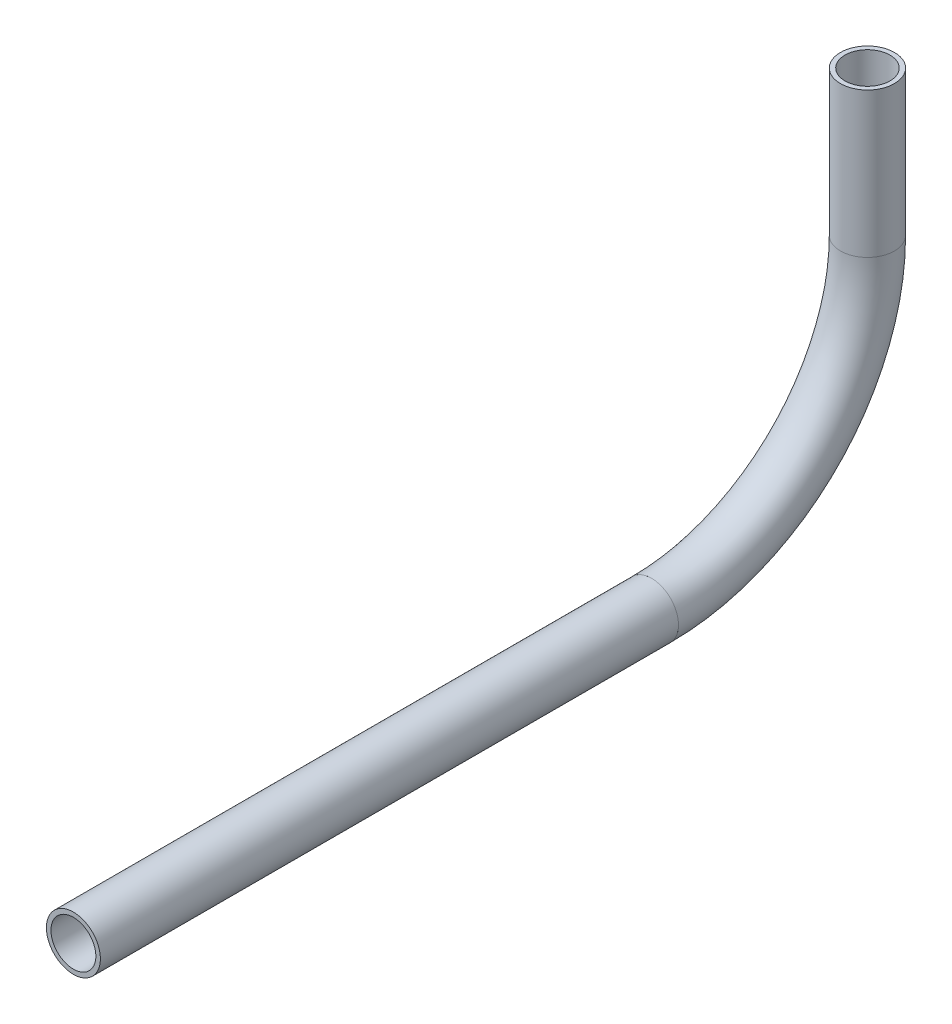
from build123d import *

# Parameters (mm, degrees)
SKETCH11_R                = 6.35
SKETCH11_R_2              = 5.2832
PIPE_0_5_SCH_40_1_DEPTH   = 136.005637638
SKETCH11_ON_SEGMENT_2_R   = 6.35
SKETCH11_ON_SEGMENT_2_R_2 = 5.2832
PIPE_0_5_SCH_40_1_2_ANGLE = 90
SKETCH11_ON_SEGMENT_3_R   = 6.35
SKETCH11_ON_SEGMENT_3_R_2 = 5.2832
PIPE_0_5_SCH_40_1_3_DEPTH = 34.109012351


with BuildPart() as part:
    # Sketch11 → Pipe 0.5 SCH 40(1) (new body)
    with BuildSketch(Plane(origin=(0, 599.960019272, 303.164595711), x_dir=(0, 1, 0), z_dir=(0, 0, -1))):
        Circle(SKETCH11_R)
        Circle(SKETCH11_R_2, mode=Mode.SUBTRACT)
    extrude(amount=PIPE_0_5_SCH_40_1_DEPTH)


with BuildPart() as body_2:
    # Sketch11 on segment 2 (carried to the start of arc 2) → Pipe 0.5 SCH 40_1 2 (revolve)
    with BuildSketch(Plane(origin=(0, 599.960019272, 167.158958073), x_dir=(0, 1, 0), z_dir=(0, 0, -1))):
        Circle(SKETCH11_ON_SEGMENT_2_R)
        Circle(SKETCH11_ON_SEGMENT_2_R_2, mode=Mode.SUBTRACT)
    revolve(axis=Axis((0, 650.760019272, 167.158958073), (1, 0, 0)), revolution_arc=PIPE_0_5_SCH_40_1_2_ANGLE)


with BuildPart() as body_3:
    # Sketch11 on segment 3 (carried to segment 3) → Pipe 0.5 SCH 40_1 3 (new body)
    with BuildSketch(Plane(origin=(0, 650.760019272, 116.358958073), x_dir=(0, 0, 1), z_dir=(0, 1, 0))):
        Circle(SKETCH11_ON_SEGMENT_3_R)
        Circle(SKETCH11_ON_SEGMENT_3_R_2, mode=Mode.SUBTRACT)
    extrude(amount=PIPE_0_5_SCH_40_1_3_DEPTH)


solid = Compound([part.part, body_2.part, body_3.part])
